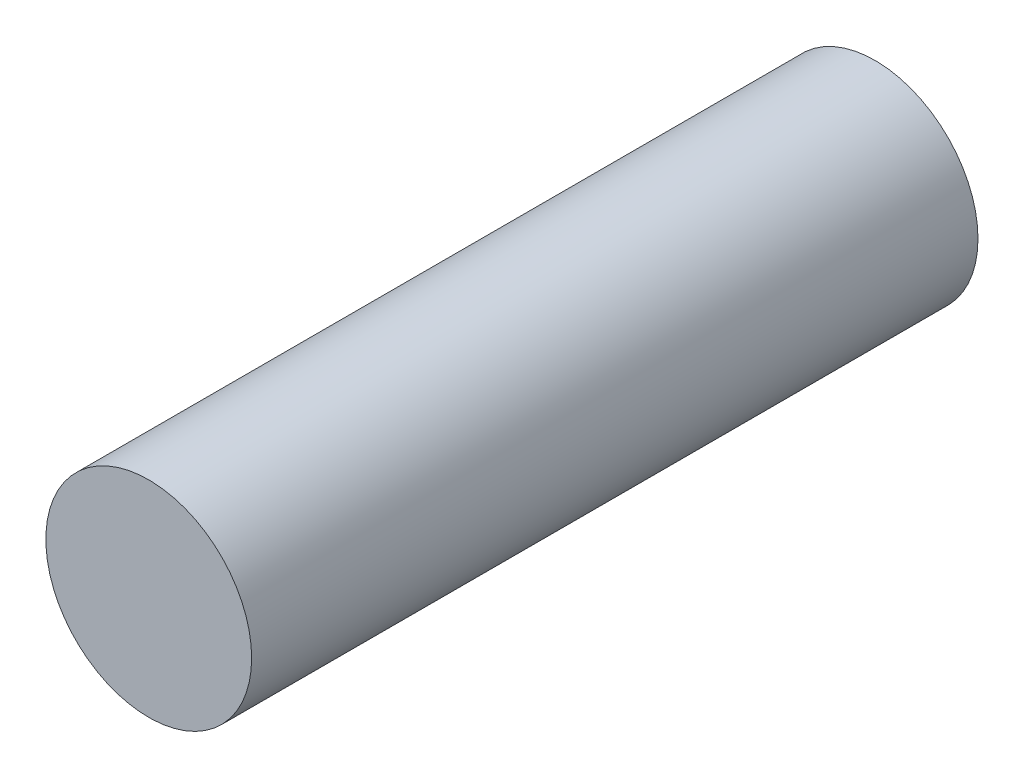
from build123d import *

# Parameters (mm, degrees)
SKETCH1_R           = 42.5
BOSS_EXTRUDE1_DEPTH = 300


with BuildPart() as part:
    # Sketch1 → Boss-Extrude1 (new body)
    with BuildSketch(Plane.XY):
        Circle(SKETCH1_R)
    extrude(amount=BOSS_EXTRUDE1_DEPTH)


solid = part.part
